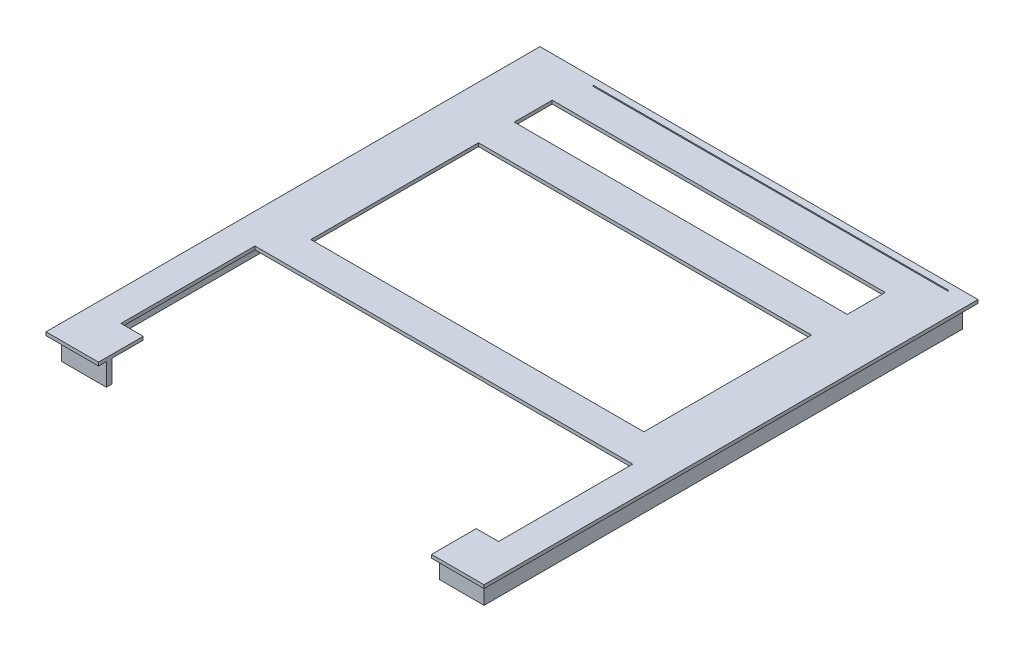
from build123d import *

# Parameters (mm, degrees)
SKETCH_1_W           = 196
SKETCH_1_H           = 221
EXTRUDE_1_DEPTH      = 1.5
EXTRUDE_2_DEPTH      = 1.5
EXTRUDE_2_DEPTH_BACK = 10
SKETCH_4_W           = 159
SKETCH_4_H           = 3
EXTRUDE_3_DEPTH      = 1.5
SKETCH_8_W           = 159
SKETCH_8_H           = 0.5
SKETCH_8_W_2         = 149
SKETCH_8_H_2         = 75
SKETCH_8_H_3         = 17
CUT_EXTRUDE_5_DEPTH  = 41.5


with BuildPart() as part:
    # 草图1 → 凸台-拉伸1 (new body)
    with BuildSketch(Plane(origin=(0, 0, 0), x_dir=(1, 0, 0), z_dir=(0, 1, 0))):
        with Locations((98, 110.5)):
            Rectangle(SKETCH_1_W, SKETCH_1_H)
    extrude(amount=EXTRUDE_1_DEPTH)

    # 草图3 → 凸台-拉伸2 (add, two sides)
    with BuildSketch(Plane(origin=(0, 0, 0), x_dir=(1, 0, 0), z_dir=(0, 1, 0))) as extrude_2_sk:
        Polygon((3.5, 217.5), (27, 217.5), (27, 216.5), (186, 216.5), (186, 217.5), (192.5, 217.5), (192.5, 6), (192.5, 3.5), (172.5, 3.5), (172.5, 6), (190, 6), (190, 215), (6, 215), (6, 6), (23.5, 6), (23.5, 3.5), (3.5, 3.5), align=None)
    extrude(amount=EXTRUDE_2_DEPTH)
    extrude(extrude_2_sk.sketch, amount=-EXTRUDE_2_DEPTH_BACK)

    # 草图4 → 凸台-拉伸3 (add)
    with BuildSketch(Plane(origin=(0, 0, 0), x_dir=(1, 0, 0), z_dir=(0, 1, 0))):
        with Locations((106.5, 219.5)):
            Rectangle(SKETCH_4_W, SKETCH_4_H)
    extrude(amount=-EXTRUDE_3_DEPTH)

    # 草图8 → 切除-拉伸5 (cut)
    with BuildSketch(Plane(origin=(0, 1.5, 0), x_dir=(1, 0, 0), z_dir=(0, 1, 0))):
        Polygon((23.5, 0), (172.5, 0), (172.5, 20), (182.5, 20), (182.5, 80), (172.5, 80), (23.5, 80), (13.5, 80), (13.5, 20), (23.5, 20), align=None)
        with Locations((106.5, 217.75)):
            Rectangle(SKETCH_8_W, SKETCH_8_H)
        with Locations((98, 132.5)):
            Rectangle(SKETCH_8_W_2, SKETCH_8_H_2)
        with Locations((98, 194.5)):
            Rectangle(SKETCH_8_W_2, SKETCH_8_H_3)
    extrude(amount=-CUT_EXTRUDE_5_DEPTH, mode=Mode.SUBTRACT)


solid = part.part
